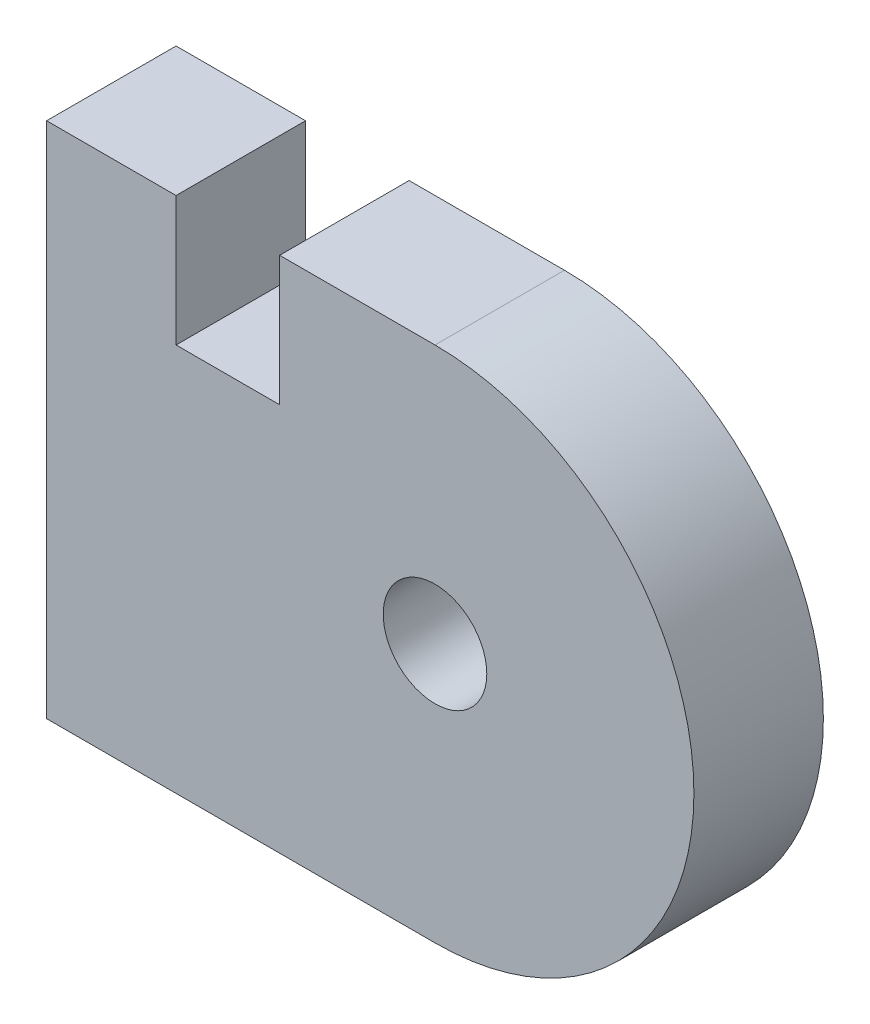
from build123d import *

# Parameters (mm, degrees)
SKETCH1_R           = 2
BOSS_EXTRUDE1_DEPTH = 5


with BuildPart() as part:
    # Sketch1 → Boss-Extrude1 (new body)
    with BuildSketch(Plane.XY):
        with BuildLine():
            Line((-3.5, 10), (2.5, 10))
            ThreePointArc((2.5, 10), (12.5, 0), (2.5, -10))
            Line((2.5, -10), (-12.5, -10))
            Line((-12.5, -10), (-12.5, 5))
            Line((-12.5, 5), (-12.5, 10))
            Line((-12.5, 10), (-7.5, 10))
            Line((-7.5, 10), (-7.5, 5))
            Line((-7.5, 5), (-3.5, 5))
            Line((-3.5, 5), (-3.5, 10))
        make_face()
        with Locations((2.5, 0)):
            Circle(SKETCH1_R, mode=Mode.SUBTRACT)
    extrude(amount=BOSS_EXTRUDE1_DEPTH)


solid = part.part
